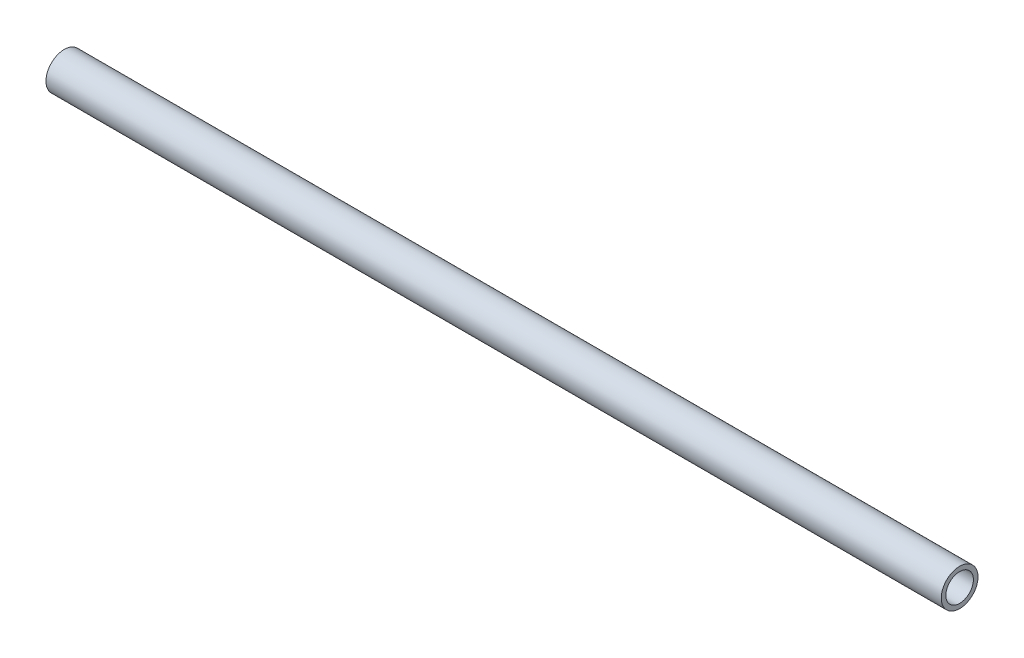
from build123d import *

# Parameters (mm, degrees)
SKETCH1_R           = 12.7
SKETCH1_R_2         = 9.525
BOSS_EXTRUDE1_DEPTH = 309.5625


with BuildPart() as part:
    # Sketch1 → Boss-Extrude1 (new body, symmetric)
    with BuildSketch(Plane(origin=(0, 0, 0), x_dir=(0, 0, -1), z_dir=(1, 0, 0))):
        Circle(SKETCH1_R)
        Circle(SKETCH1_R_2, mode=Mode.SUBTRACT)
    extrude(amount=BOSS_EXTRUDE1_DEPTH, both=True)


solid = part.part
